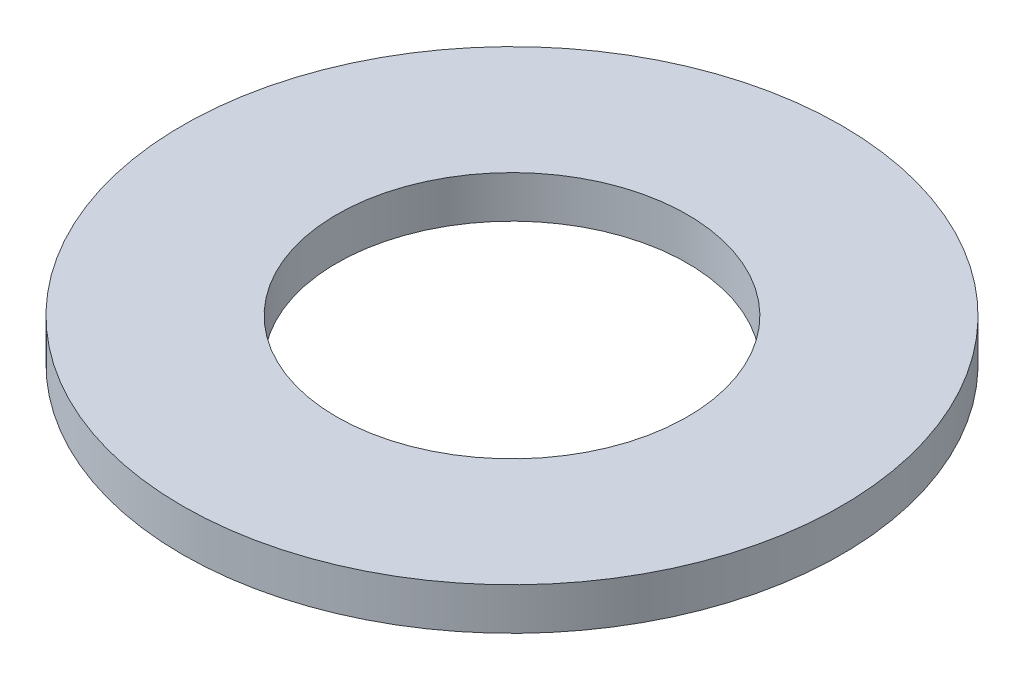
from build123d import *

# Parameters (mm, degrees)
SKETCH1_R           = 5.969
SKETCH1_R_2         = 3.175
BOSS_EXTRUDE1_DEPTH = 0.762


with BuildPart() as part:
    # Sketch1 → Boss-Extrude1 (new body)
    with BuildSketch(Plane(origin=(0, 0, 0), x_dir=(1, 0, 0), z_dir=(0, 1, 0))):
        Circle(SKETCH1_R)
        Circle(SKETCH1_R_2, mode=Mode.SUBTRACT)
    extrude(amount=BOSS_EXTRUDE1_DEPTH)


solid = part.part
